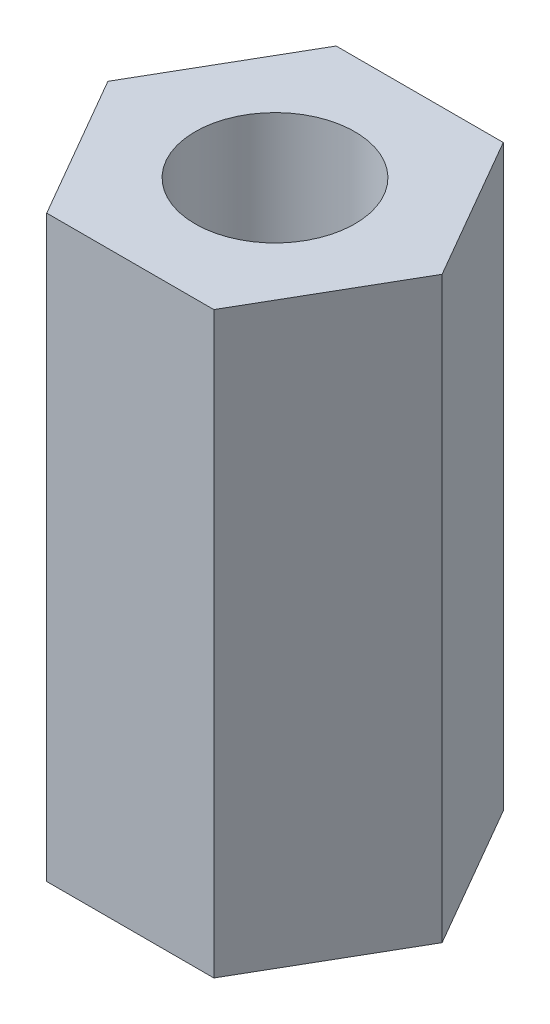
from build123d import *

# Parameters (mm, degrees)
SKETCH1_R           = 1.7526
BOSS_EXTRUDE1_DEPTH = 12.7


with BuildPart() as part:
    # Sketch1 → Boss-Extrude1 (new body)
    with BuildSketch(Plane(origin=(0, 0, 0), x_dir=(1, 0, 0), z_dir=(0, 1, 0))):
        Polygon((3.666174209, 0), (1.833087105, 3.175), (-1.833087105, 3.175), (-3.666174209, 0), (-1.833087105, -3.175), (1.833087105, -3.175), align=None)
        Circle(SKETCH1_R, mode=Mode.SUBTRACT)
    extrude(amount=BOSS_EXTRUDE1_DEPTH)


solid = part.part
